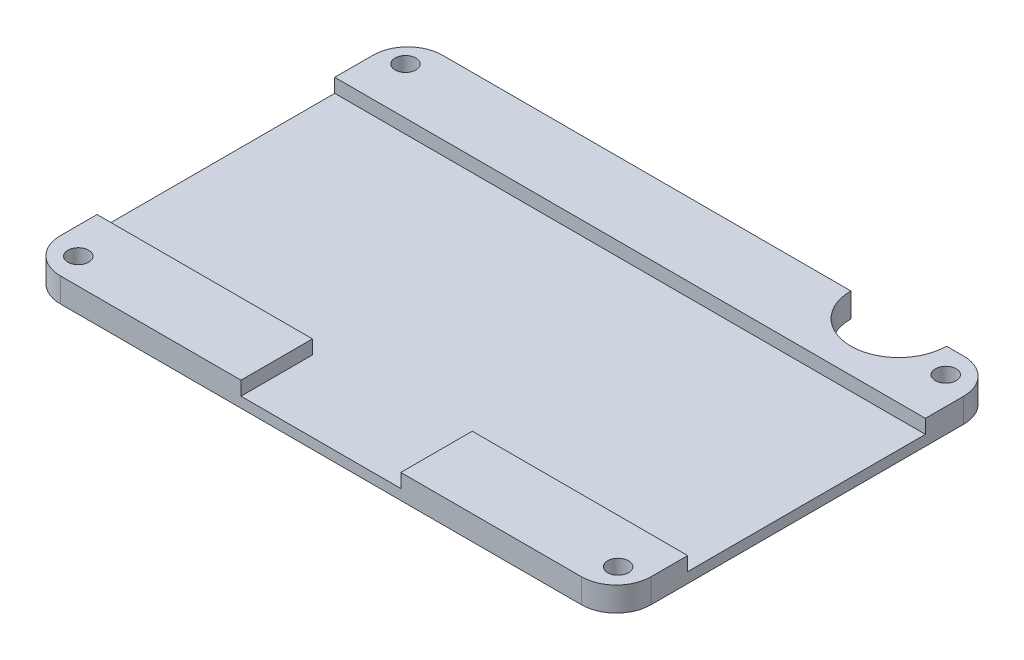
from build123d import *

# Parameters (mm, degrees)
BOSS_EXTRUDE1_DEPTH = 3.5
SKETCH2_R           = 1.5
CUT_EXTRUDE1_DEPTH  = 3.5
SKETCH3_W           = 23
SKETCH3_H           = 10.283770076
CUT_EXTRUDE2_DEPTH  = 2
CUT_EXTRUDE6_DEPTH  = 3.5


with BuildPart() as part:
    # Sketch1 → Boss-Extrude1 (new body)
    with BuildSketch(Plane(origin=(0, 0, 0), x_dir=(1, 0, 0), z_dir=(0, 1, 0))):
        with BuildLine():
            Line((-20.62248996, 7.565261044), (54.37751004, 7.565261044))
            ThreePointArc((54.37751004, 7.565261044), (57.913043946, 6.10079495), (59.37751004, 2.565261044))
            Line((59.37751004, 2.565261044), (59.37751004, -42.434738956))
            ThreePointArc((59.37751004, -42.434738956), (57.913043946, -45.970272862), (54.37751004, -47.434738956))
            Line((54.37751004, -47.434738956), (-20.62248996, -47.434738956))
            ThreePointArc((-20.62248996, -47.434738956), (-24.158023866, -45.970272862), (-25.62248996, -42.434738956))
            Line((-25.62248996, -42.434738956), (-25.62248996, 2.565261044))
            ThreePointArc((-25.62248996, 2.565261044), (-24.158023866, 6.10079495), (-20.62248996, 7.565261044))
        make_face()
    extrude(amount=BOSS_EXTRUDE1_DEPTH)

    # Sketch2 → Cut-Extrude1 (cut)
    with BuildSketch(Plane(origin=(0, 3.5, 0), x_dir=(1, 0, 0), z_dir=(0, 1, 0))):
        with Locations((-22.187566987, 3.802718615)):
            Circle(SKETCH2_R)
        with Locations((55.412433013, 3.947865339)):
            Circle(SKETCH2_R)
        with Locations((55.766505812, -43.552134661)):
            Circle(SKETCH2_R)
        with Locations((-21.775437199, -43.697281385)):
            Circle(SKETCH2_R)
    extrude(amount=-CUT_EXTRUDE1_DEPTH, mode=Mode.SUBTRACT)

    # Sketch3 → Cut-Extrude2 (cut)
    with BuildSketch(Plane(origin=(0, 3.5, 0), x_dir=(1, 0, 0), z_dir=(0, 1, 0))):
        with Locations((16.87751004, -42.292853918)):
            Rectangle(SKETCH3_W, SKETCH3_H)
        Polygon((59.37751004, -2.947281385), (-25.62248996, -2.947281385), (-25.62248996, -37.15096888), (5.37751004, -37.15096888), (28.37751004, -37.15096888), (59.37751004, -37.15096888), align=None)
    extrude(amount=-CUT_EXTRUDE2_DEPTH, mode=Mode.SUBTRACT)

    # Sketch9 → Cut-Extrude6 (cut)
    with BuildSketch(Plane(origin=(0, 3.5, 0), x_dir=(1, 0, 0), z_dir=(0, 1, 0))):
        with BuildLine():
            Line((38.139406345, 7.565261044), (51.719818859, 7.565261044))
            Line((51.719818859, 7.565261044), (51.90057812, 7.565261044))
            ThreePointArc((51.90057812, 7.565261044), (45.019992232, 0.684675157), (38.139406345, 7.565261044))
        make_face()
    extrude(amount=-CUT_EXTRUDE6_DEPTH, mode=Mode.SUBTRACT)


solid = part.part
